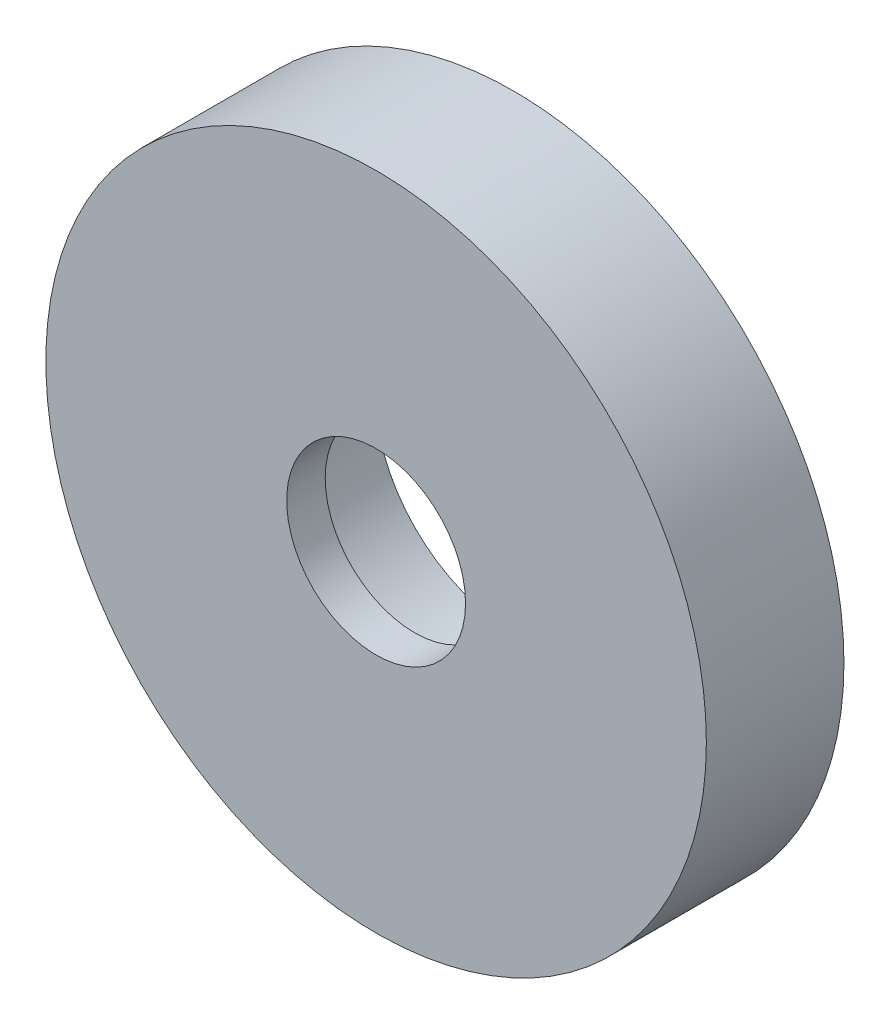
from build123d import *

# Parameters (mm, degrees)
SKETCH1_R               = 19.05
SKETCH1_R_2             = 8.001
BOSS_EXTRUDE1_DEPTH     = 3.175
SKETCH2_R               = 19.05
BOSS_EXTRUDE2_DEPTH     = 4.7625
F_3_8_CLEARANCE_HOLE1_D = 10.31748
SKETCH6_R               = 8.001
CUT_EXTRUDE1_DEPTH      = 2.54


with BuildPart() as part:
    # Sketch1 → Boss-Extrude1 (new body)
    with BuildSketch(Plane.XY):
        with Locations((95.864074702, 45.465579041)):
            Circle(SKETCH1_R)
        with Locations((95.864074702, 45.465579041)):
            Circle(SKETCH1_R_2, mode=Mode.SUBTRACT)
    extrude(amount=-BOSS_EXTRUDE1_DEPTH)

    # Sketch2 → Boss-Extrude2 (add)
    with BuildSketch(Plane.XY):
        with Locations((95.864074702, 45.465579041)):
            Circle(SKETCH2_R)
    extrude(amount=BOSS_EXTRUDE2_DEPTH)

    # 3/8 Clearance Hole1 (through all)
    with Locations(Plane.XY.offset(4.7625)):
        with Locations((95.864074702, 45.465579041)):
            Hole(F_3_8_CLEARANCE_HOLE1_D / 2)

    # Sketch6 → Cut-Extrude1 (cut)
    with BuildSketch(Plane(origin=(0, 0, 0), x_dir=(-1, 0, 0), z_dir=(0, 0, -1))):
        with Locations((-95.864074702, 45.465579041)):
            Circle(SKETCH6_R)
    extrude(amount=-CUT_EXTRUDE1_DEPTH, mode=Mode.SUBTRACT)


solid = part.part
